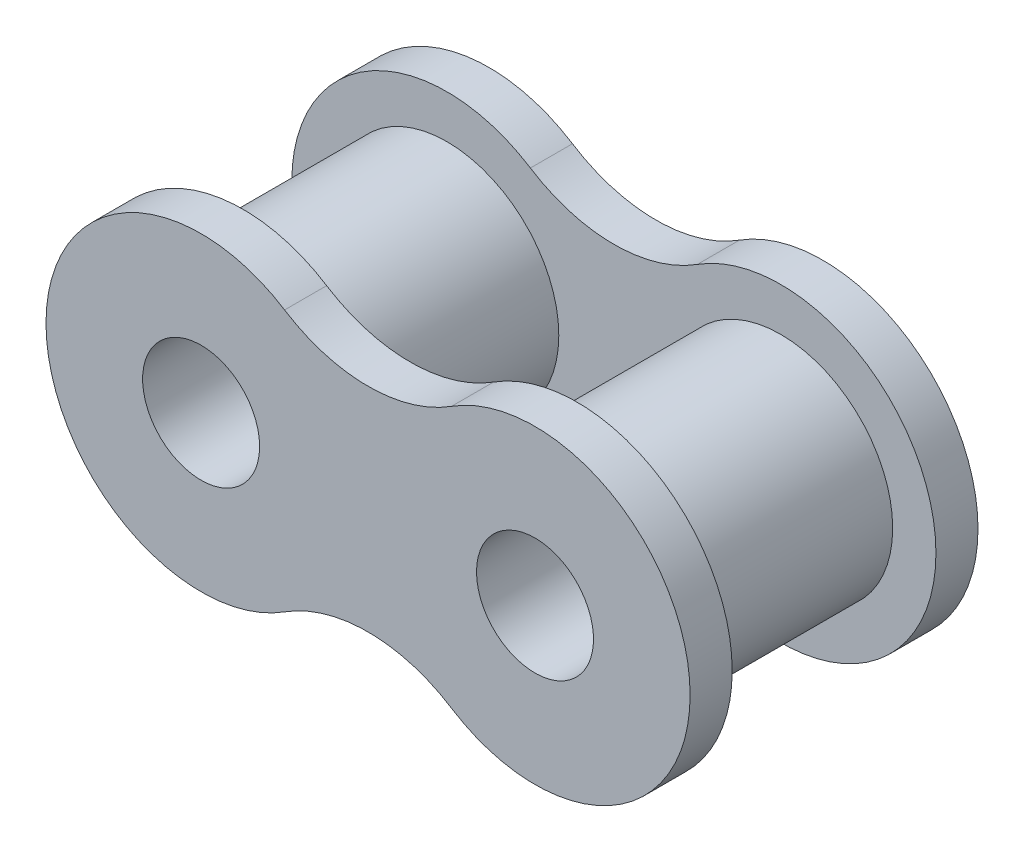
from build123d import *

# Parameters (mm, degrees)
EXTRUDE_START   = -3.875
SKETCH_1_R      = 2.225
EXTRUDE_1_DEPTH = 1.6
SKETCH_1_3_R    = 4.255
SKETCH_1_3_R_2  = 2.225
EXTRUDE_2_DEPTH = 3.875


with BuildPart() as part:
    # Эскиз1 → Бобышка-Вытянуть1 (new body)
    with BuildSketch(Plane.XY.offset(EXTRUDE_START)):
        with BuildLine():
            Line((0, 4.045727726), (0, -4.045727726))
            ThreePointArc((0, -4.045727726), (-1.653799143, -4.282252786), (-3.175, -4.972863863))
            ThreePointArc((-3.175, -4.972863863), (-12.25, 0), (-3.175, 4.972863863))
            ThreePointArc((-3.175, 4.972863863), (-1.653799143, 4.282252786), (0, 4.045727726))
        make_face()
        with Locations((-6.35, 0)):
            Circle(SKETCH_1_R, mode=Mode.SUBTRACT)
    extrude(amount=-EXTRUDE_1_DEPTH)

    # Эскиз1<3> → Бобышка-Вытянуть2 (add)
    with BuildSketch(Plane.XY):
        with Locations((-6.35, 0)):
            Circle(SKETCH_1_3_R)
        with Locations((-6.35, 0)):
            Circle(SKETCH_1_3_R_2, mode=Mode.SUBTRACT)
    extrude(amount=-EXTRUDE_2_DEPTH)

    # Зеркальное отражение1: part across plane


with BuildPart() as part_1:
    add(part.part)
    add(part.part.mirror(Plane(origin=(0, 0, 0), x_dir=(0, 0, 1), z_dir=(1, 0, 0))))

    # Зеркальное отражение2: part across plane


with BuildPart() as part_2:
    add(part_1.part)
    add(part_1.part.mirror(Plane.XY))


solid = part_2.part
